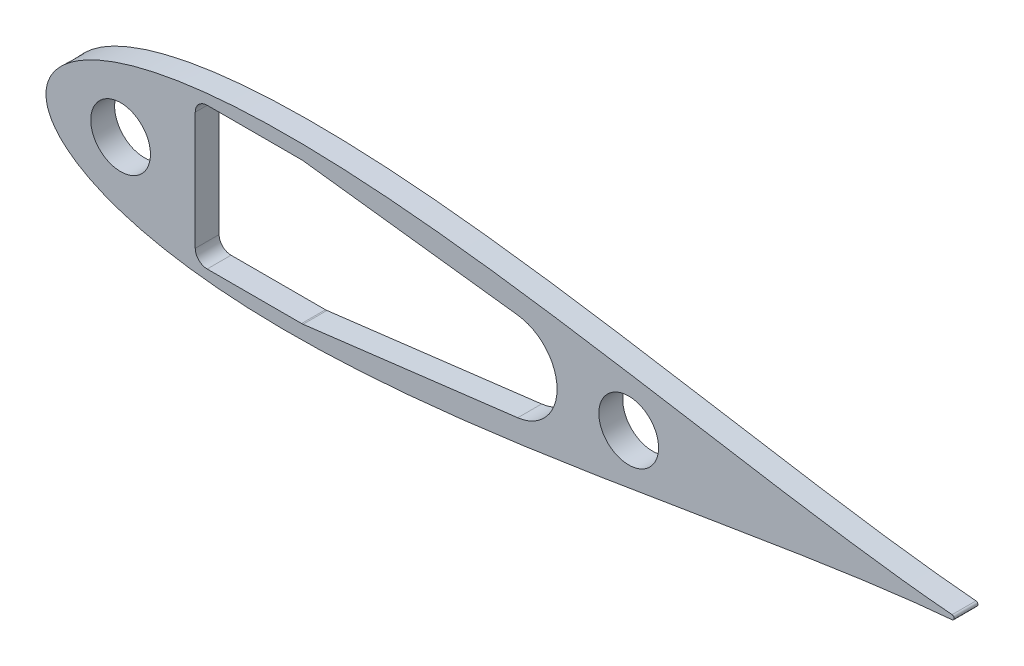
from build123d import *

# Parameters (mm, degrees)
BOSS_EXTRUDE1_DEPTH = 5.4737
SCALE1_SCALE        = 0.3
BOSS_EXTRUDE2_DEPTH = 5.08
SKETCH10_W          = 25.167167629
SKETCH10_H          = 30.1625
CUT_EXTRUDE6_DEPTH  = 6.0800001
FILLET1_R           = 2.54
CUT_EXTRUDE8_DEPTH  = 6.0800001
CUT_EXTRUDE9_DEPTH  = 6.0800001
SKETCH19_R          = 6.35
CUT_EXTRUDE10_DEPTH = 6.0800001


with BuildPart() as part:
    # Sketch2 → Boss-Extrude1 (new body)
    with BuildSketch(Plane.XY):
        with BuildLine():
            add(Edge.make_bspline(
                [(642.510849283, 1.582039112), (641.993392355, 1.625070631), (638.093728429, 1.953546407), (630.413817462, 2.663385493), (619.014124193, 3.849253664), (606.374988512, 5.304428983), (592.543922516, 7.037634907), (577.585454095, 9.050636147), (561.564270734, 11.338919625), (544.549749946, 13.890665375), (526.614143658, 16.687720753), (507.832591566, 19.705111663), (488.282710288, 22.911672601), (468.044367735, 26.27043606), (447.199424328, 29.739007432), (425.831595832, 33.270324121), (404.02631566, 36.813220545), (381.870662856, 40.313266856), (359.453314895, 43.713502532), (336.86454415, 46.955447457), (314.196207315, 49.979843895), (291.541767704, 52.727712704), (268.996310773, 55.141201012), (246.65655865, 57.164603829), (224.620860897, 58.745176641), (202.989192599, 59.8341217), (181.863132616, 60.387506142), (161.345829027, 60.366961324), (141.542033828, 59.739895824), (122.558104573, 58.481758104), (104.502313427, 56.574303932), (87.485018636, 54.008935199), (71.619696083, 50.784752003), (57.023709725, 46.912543066), (43.82045433, 42.41500246), (32.141645239, 37.332204029), (22.129107375, 31.731455339), (13.932423524, 25.726412106), (7.689616489, 19.513207632), (3.463136343, 13.420354421), (1.106333228, 7.923389435), (0.154611582, 3.513796615), (-0.062151598, 0), (0.154611582, -3.513796615), (1.106333228, -7.923389435), (3.463136343, -13.420354421), (7.689616489, -19.513207632), (13.932423524, -25.726412106), (22.129107375, -31.731455339), (32.141645239, -37.332204029), (43.82045433, -42.41500246), (57.023709725, -46.912543066), (71.619696083, -50.784752003), (87.485018636, -54.008935199), (104.502313427, -56.574303932), (122.558104573, -58.481758104), (141.542033828, -59.739895824), (161.345829027, -60.366961324), (181.863132616, -60.387506142), (202.989192599, -59.8341217), (224.620860897, -58.745176641), (246.65655865, -57.164603829), (268.996310773, -55.141201012), (291.541767704, -52.727712704), (314.196207315, -49.979843895), (336.86454415, -46.955447457), (359.453314895, -43.713502532), (381.870662856, -40.313266856), (404.02631566, -36.813220545), (425.831595832, -33.270324121), (447.199424328, -29.739007432), (468.044367735, -26.27043606), (488.282710288, -22.911672601), (507.832591566, -19.705111663), (526.614143658, -16.687720753), (544.549749946, -13.890665375), (561.564270734, -11.338919625), (577.585454095, -9.050636147), (592.543922516, -7.037634907), (606.374988512, -5.304428983), (619.014124193, -3.849253664), (630.413817462, -2.663385493), (638.093728429, -1.953546407), (641.993392355, -1.625070631), (642.510849283, -1.582039112)],
                knots=[0.020157042, 0.020157042, 0.020157042, 0.020157042, 0.021270888, 0.028552555, 0.036780684, 0.045920102, 0.055931764, 0.066772884, 0.07839713, 0.090754827, 0.103793165, 0.117456432, 0.131686226, 0.146421738, 0.161599998, 0.177156133, 0.193023668, 0.209134786, 0.225420633, 0.241811602, 0.258237647, 0.274628557, 0.290914287, 0.307025229, 0.322892517, 0.338448342, 0.353626207, 0.368361232, 0.382590428, 0.396252961, 0.409290412, 0.42164701, 0.433269881, 0.444109249, 0.45411864, 0.463255055, 0.471479114, 0.478755289, 0.485052318, 0.490344026, 0.494609833, 0.497833231, 0.5, 0.502166769, 0.505390167, 0.509655974, 0.514947682, 0.521244711, 0.528520886, 0.536744945, 0.54588136, 0.555890751, 0.566730119, 0.57835299, 0.590709588, 0.603747039, 0.617409572, 0.631638768, 0.646373793, 0.661551658, 0.677107483, 0.692974771, 0.709085713, 0.725371443, 0.741762353, 0.758188398, 0.774579367, 0.790865214, 0.806976332, 0.822843867, 0.838400002, 0.853578262, 0.868313774, 0.882543568, 0.896206835, 0.909245173, 0.92160287, 0.933227116, 0.944068236, 0.954079898, 0.963219316, 0.971447445, 0.978729112, 0.979842958, 0.979842958, 0.979842958, 0.979842958], degree=3))
            ThreePointArc((642.510849283, -1.582039112), (643.966787522, 0), (642.510849283, 1.582039112))
        make_face()
    extrude(amount=BOSS_EXTRUDE1_DEPTH)


with BuildPart() as part_1:
    # Scale1: scaled about (0, 0, 0)
    add(part.part.scale(SCALE1_SCALE))

    # Sketch11 → Boss-Extrude2 (add)
    with BuildSketch(Plane(origin=(0, 0, 0), x_dir=(-1, 0, 0), z_dir=(0, 0, -1))):
        with BuildLine():
            ThreePointArc((-192.753254785, 0.474611734), (-193.190036257, 0), (-192.753254785, -0.474611734))
            add(Edge.make_bspline(
                [(-192.753254785, -0.474611734), (-192.598017706, -0.487521189), (-191.428118529, -0.586063922), (-189.124145239, -0.799015648), (-185.704237258, -1.154776099), (-181.912496554, -1.591328695), (-177.763176755, -2.111290472), (-173.275636229, -2.715190844), (-168.46928122, -3.401675887), (-163.364924984, -4.167199612), (-157.984243097, -5.006316226), (-152.34977747, -5.911533499), (-146.484813087, -6.87350178), (-140.41331032, -7.881130818), (-134.159827298, -8.92170223), (-127.74947875, -9.981097236), (-121.207894698, -11.043966164), (-114.561198857, -12.093980057), (-107.835994469, -13.11405076), (-101.059363245, -14.086634237), (-94.258862195, -14.993953169), (-87.462530311, -15.818313811), (-80.698893232, -16.542360303), (-73.996967595, -17.149381149), (-67.386258269, -17.623552992), (-60.89675778, -17.95023651), (-54.558939785, -18.116251843), (-48.403748708, -18.110088397), (-42.462610148, -17.921968747), (-36.767431372, -17.544527431), (-31.350694028, -16.97229118), (-26.245505591, -16.20268056), (-21.485908825, -15.235425601), (-17.107112917, -14.07376292), (-13.146136299, -12.724500738), (-9.642493572, -11.199661209), (-6.638732213, -9.519436602), (-4.179727057, -7.717923632), (-2.306884947, -5.85396229), (-1.038940903, -4.026106326), (-0.331899968, -2.37701683), (-0.046383474, -1.054138985), (0.018645479, 0), (-0.046383474, 1.054138985), (-0.331899968, 2.37701683), (-1.038940903, 4.026106326), (-2.306884947, 5.85396229), (-4.179727057, 7.717923632), (-6.638732213, 9.519436602), (-9.642493572, 11.199661209), (-13.146136299, 12.724500738), (-17.107112917, 14.07376292), (-21.485908825, 15.235425601), (-26.245505591, 16.20268056), (-31.350694028, 16.97229118), (-36.767431372, 17.544527431), (-42.462610148, 17.921968747), (-48.403748708, 18.110088397), (-54.558939785, 18.116251843), (-60.89675778, 17.95023651), (-67.386258269, 17.623552992), (-73.996967595, 17.149381149), (-80.698893232, 16.542360303), (-87.462530311, 15.818313811), (-94.258862195, 14.993953169), (-101.059363245, 14.086634237), (-107.835994469, 13.11405076), (-114.561198857, 12.093980057), (-121.207894698, 11.043966164), (-127.74947875, 9.981097236), (-134.159827298, 8.92170223), (-140.41331032, 7.881130818), (-146.484813087, 6.87350178), (-152.34977747, 5.911533499), (-157.984243097, 5.006316226), (-163.364924984, 4.167199612), (-168.46928122, 3.401675887), (-173.275636229, 2.715190844), (-177.763176755, 2.111290472), (-181.912496554, 1.591328695), (-185.704237258, 1.154776099), (-189.124145239, 0.799015648), (-191.428118529, 0.586063922), (-192.598017706, 0.487521189), (-192.753254785, 0.474611734)],
                knots=[0.020157042, 0.020157042, 0.020157042, 0.020157042, 0.021270888, 0.028552555, 0.036780684, 0.045920102, 0.055931764, 0.066772884, 0.07839713, 0.090754827, 0.103793165, 0.117456432, 0.131686226, 0.146421738, 0.161599998, 0.177156133, 0.193023668, 0.209134786, 0.225420633, 0.241811602, 0.258237647, 0.274628557, 0.290914287, 0.307025229, 0.322892517, 0.338448342, 0.353626207, 0.368361232, 0.382590428, 0.396252961, 0.409290412, 0.42164701, 0.433269881, 0.444109249, 0.45411864, 0.463255055, 0.471479114, 0.478755289, 0.485052318, 0.490344026, 0.494609833, 0.497833231, 0.5, 0.502166769, 0.505390167, 0.509655974, 0.514947682, 0.521244711, 0.528520886, 0.536744945, 0.54588136, 0.555890751, 0.566730119, 0.57835299, 0.590709588, 0.603747039, 0.617409572, 0.631638768, 0.646373793, 0.661551658, 0.677107483, 0.692974771, 0.709085713, 0.725371443, 0.741762353, 0.758188398, 0.774579367, 0.790865214, 0.806976332, 0.822843867, 0.838400002, 0.853578262, 0.868313774, 0.882543568, 0.896206835, 0.909245173, 0.92160287, 0.933227116, 0.944068236, 0.954079898, 0.963219316, 0.971447445, 0.978729112, 0.979842958, 0.979842958, 0.979842958, 0.979842958], degree=3))
        make_face()
    extrude(amount=-BOSS_EXTRUDE2_DEPTH)

    # Sketch10 → Cut-Extrude6 (cut, through all)
    with BuildSketch(Plane.XY):
        with Locations((44.333583815, 0)):
            Rectangle(SKETCH10_W, SKETCH10_H)
    extrude(amount=CUT_EXTRUDE6_DEPTH, mode=Mode.SUBTRACT)

    # Fillet1
    fillet1_edges = [part_1.edges().sort_by_distance(p)[0] for p in [
        (56.917167629, -15.08125, 2.54),
        (56.917167629, 15.08125, 2.54),
        (31.75, 15.08125, 2.54),
        (31.75, -15.08125, 2.54),
    ]]
    fillet(fillet1_edges, radius=FILLET1_R)

    # Sketch16 → Cut-Extrude8 (cut, through all)
    with BuildSketch(Plane.XY.offset(5.08)):
        with BuildLine():
            Line((99.197583815, -9.525), (97.419583815, -9.525))
            ThreePointArc((97.419583815, -9.525), (87.894583815, 0), (97.419583815, 9.525))
            Line((97.419583815, 9.525), (99.197583815, 9.525))
            ThreePointArc((99.197583815, 9.525), (108.722583815, 0), (99.197583815, -9.525))
        make_face()
    extrude(amount=-CUT_EXTRUDE8_DEPTH, mode=Mode.SUBTRACT)

    # Sketch18 → Cut-Extrude9 (cut, through all)
    with BuildSketch(Plane.XY.offset(5.08)):
        with BuildLine():
            Line((54.686745058, 15.062313628), (100.358499174, 9.453988604))
            ThreePointArc((100.358499174, 9.453988604), (108.722583815, 0), (100.358499174, -9.453988604))
            Line((100.358499174, -9.453988604), (54.686745058, -15.062313628))
            ThreePointArc((54.686745058, -15.062313628), (56.279524939, -14.224293869), (56.917167629, -12.54125))
            Line((56.917167629, -12.54125), (56.917167629, 12.54125))
            ThreePointArc((56.917167629, 12.54125), (56.279524939, 14.224293869), (54.686745058, 15.062313628))
        make_face()
    extrude(amount=-CUT_EXTRUDE9_DEPTH, mode=Mode.SUBTRACT)

    # Sketch19 → Cut-Extrude10 (cut, through all)
    with BuildSketch(Plane.XY.offset(5.08)):
        with Locations((15.875, 0)):
            Circle(SKETCH19_R)
        with Locations((123.962583815, 0)):
            Circle(SKETCH19_R)
    extrude(amount=-CUT_EXTRUDE10_DEPTH, mode=Mode.SUBTRACT)


solid = part_1.part
